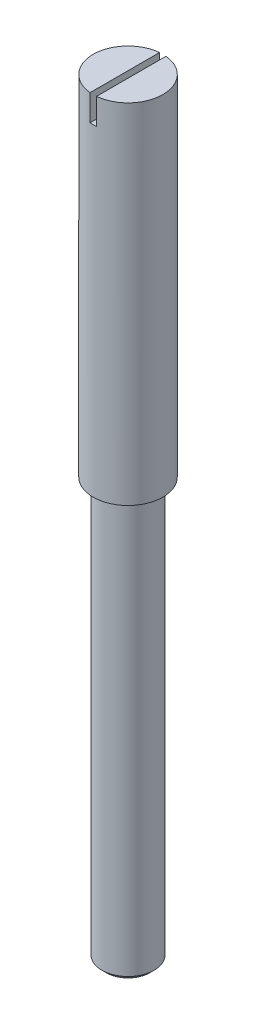
from build123d import *

# Parameters (mm, degrees)
SKETCH2_W               = 0.093
SKETCH2_H               = 0.722554603
CUT_EXTRUDE1_DEPTH      = 1.5
CUT_EXTRUDE1_DEPTH_BACK = 1.5
CHAMFER1_SIZE           = 0.062


with BuildPart() as part:
    # Sketch1 → Revolve1 (revolve)
    with BuildSketch(Plane.XY):
        Polygon((0, 0), (0.375, 0), (0.375, 6), (0.5, 6), (0.5, 11), (0, 11), align=None)
    revolve(axis=Axis((0, -1.490059703, 0), (0, 1, 0)))

    # Sketch2 → Cut-Extrude1 (cut, two sides)
    with BuildSketch(Plane.XY) as cut_extrude1_sk:
        with Locations((0, 10.987009479)):
            Rectangle(SKETCH2_W, SKETCH2_H)
    extrude(amount=CUT_EXTRUDE1_DEPTH, mode=Mode.SUBTRACT)
    extrude(cut_extrude1_sk.sketch, amount=-CUT_EXTRUDE1_DEPTH_BACK, mode=Mode.SUBTRACT)

    # Chamfer1
    chamfer1_edges = [part.edges().sort_by_distance(p)[0] for p in [
        (-0.375, 0, 0),
    ]]
    chamfer(chamfer1_edges, length=CHAMFER1_SIZE)


solid = part.part
